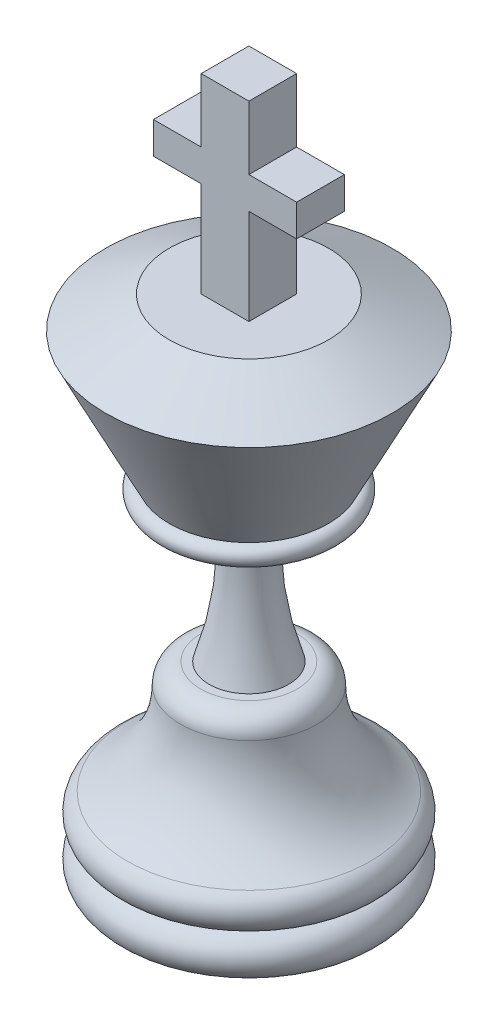
from build123d import *

# Parameters (mm, degrees)
BOSS_EXTRUDE1_DEPTH      = 19.05
BOSS_EXTRUDE1_DEPTH_BACK = 19.05


with BuildPart() as part:
    # Sketch1 → Revolve2 (revolve)
    with BuildSketch(Plane.XY):
        with BuildLine():
            Line((0, 0), (88.9, 0))
            ThreePointArc((88.9, 0), (105.111562458, 16.211562458), (88.9, 32.423124915))
            ThreePointArc((88.9, 32.423124915), (104.559166862, 44.438826258), (97.005781229, 62.674312296))
            ThreePointArc((97.005781229, 62.674312296), (65.935055983, 93.745037542), (54.562381229, 136.188437542))
            ThreePointArc((54.562381229, 136.188437542), (49.814124519, 147.65174329), (38.350818771, 152.4))
            Line((38.350818771, 152.4), (0, 152.4))
            Line((0, 152.4), (0, 0))
        make_face()
    revolve(axis=Axis((0, 0, 0), (0, 1, 0)))

    # Sketch3 → Revolve4 (revolve)
    with BuildSketch(Plane.XY):
        with BuildLine():
            Line((0, 152.4), (0, 279.4))
            Line((0, 279.4), (63.5, 279.4))
            ThreePointArc((63.5, 279.4), (71.12, 271.78), (63.5, 264.16))
            ThreePointArc((63.5, 264.16), (40.692939654, 261.567060346), (19.05, 253.920590519))
            ThreePointArc((19.05, 253.920590519), (20.235490937, 202.514226666), (31.75, 152.4))
            Line((31.75, 152.4), (0, 152.4))
        make_face()
    revolve(axis=Axis((0, 152.4, 0), (0, 1, 0)))

    # Sketch4 → Revolve5 (revolve)
    with BuildSketch(Plane.XY):
        Polygon((0, 279.4), (0, 406.4), (63.5, 406.4), (114.3, 381), (63.5, 279.4), align=None)
    revolve(axis=Axis((0, 279.4, 0), (0, -1, 0)))

    # Sketch5 → Boss-Extrude1 (add, two sides: drawn at the far end of the back side and taken through both)
    with BuildSketch(Plane.XY.offset(-BOSS_EXTRUDE1_DEPTH_BACK)):
        Polygon((19.05, 406.4), (19.05, 482.6), (57.15, 482.6), (57.15, 508), (19.05, 508), (19.05, 558.8), (-19.05, 558.8), (-19.05, 508), (-57.15, 508), (-57.15, 482.6), (-19.05, 482.6), (-19.05, 406.4), align=None)
    extrude(amount=BOSS_EXTRUDE1_DEPTH + BOSS_EXTRUDE1_DEPTH_BACK)


solid = part.part
